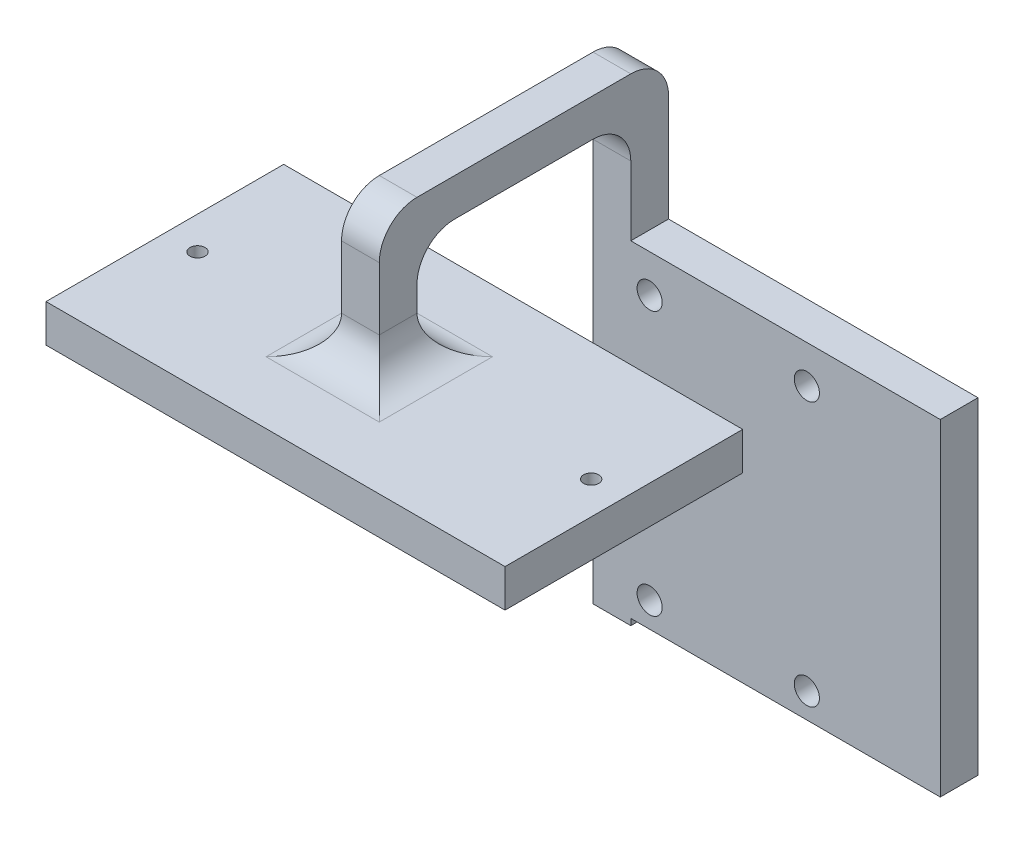
from build123d import *

# Parameters (mm, degrees)
IZIM1_W                                 = 40.658634346
IZIM1_H                                 = 22.072921898
Y_KSEKLIK_EKSTR_ZYON3_DEPTH             = 1.5
IZIM10_W                                = 40.658634346
IZIM10_H                                = 22.072921898
Y_KSEKLIK_EKSTR_ZYON5_DEPTH             = 1.5
Y_KSEKLIK_EKSTR_ZYON6_DEPTH             = 1.5
IZIM12_W                                = 40.658634346
IZIM12_H                                = 22.072921898
KES_EKSTR_ZYON1_DEPTH                   = 5
KES_EKSTR_ZYON1_DEPTH_BACK              = 3
RADYUS1_R                               = 3
Y_KSEKLIK_EKSTR_ZYON7_REACH             = 3.5
Y_KSEKLIK_EKSTR_ZYON7_DIRECTION_2_REACH = 31.45
IZIM18_R                                = 0.6
KES_EKSTR_ZYON3_DEPTH                   = 7
KES_EKSTR_ZYON3_DEPTH_BACK              = 3
SKETCH1_R                               = 1
CUT_EXTRUDE1_DEPTH                      = 3


with BuildPart() as part:
    # Çizim1 → Yükseklik-Ekstrüzyon3 (new body)
    with BuildSketch(Plane(origin=(0, 0, 0), x_dir=(1, 0, 0), z_dir=(0, 1, 0))):
        with Locations((1.2, 0)):
            Rectangle(IZIM1_W, IZIM1_H)
        with BuildLine():
            Line((1.9, -6.45), (1.9, -3.295349698))
            Line((1.9, -3.295349698), (16.626291793, -1.99221515))
            ThreePointArc((16.626291793, -1.99221515), (18.45, 0), (16.626291793, 1.99221515))
            Line((16.626291793, 1.99221515), (1.9, 3.295349698))
            Line((1.9, 3.295349698), (1.9, 6.45))
            ThreePointArc((1.9, 6.45), (0, 8.35), (-1.9, 6.45))
            Line((-1.9, 6.45), (-1.9, 2.87967012))
            ThreePointArc((-1.9, 2.87967012), (-2.057742862, 2.769150468), (-2.209072203, 2.65))
            Line((-2.209072203, 2.65), (-14.159121967, 1.99702088))
            ThreePointArc((-14.159121967, 1.99702088), (-16.05, 0), (-14.159121967, -1.99702088))
            Line((-14.159121967, -1.99702088), (-2.209072203, -2.65))
            ThreePointArc((-2.209072203, -2.65), (-2.057742862, -2.769150468), (-1.9, -2.87967012))
            Line((-1.9, -2.87967012), (-1.9, -6.45))
            ThreePointArc((-1.9, -6.45), (0, -8.35), (1.9, -6.45))
        make_face(mode=Mode.SUBTRACT)
    extrude(amount=Y_KSEKLIK_EKSTR_ZYON3_DEPTH)

    # Çizim10 → Yükseklik-Ekstrüzyon5 (add)
    with BuildSketch(Plane(origin=(0, 1.5, 0), x_dir=(1, 0, 0), z_dir=(0, 1, 0))):
        with Locations((1.2, 0)):
            Rectangle(IZIM10_W, IZIM10_H)
    extrude(amount=Y_KSEKLIK_EKSTR_ZYON5_DEPTH)

    # Çizim11 → Yükseklik-Ekstrüzyon6 (add, symmetric)
    with BuildSketch(Plane(origin=(0, 0, 0), x_dir=(0, 0, -1), z_dir=(1, 0, 0))):
        Polygon((18.5, 10.980931434), (1.5, 10.980931434), (1.5, 1.777726909), (-1.5, 1.777726909), (-1.5, 10.980931434), (-1.5, 13.980931434), (1.5, 13.980931434), (21.5, 13.980931434), (21.5, -24.019068566), (18.5, -24.019068566), align=None)
    extrude(amount=Y_KSEKLIK_EKSTR_ZYON6_DEPTH, both=True)

    # Çizim12 → Kes-Ekstrüzyon1 (cut, two sides)
    with BuildSketch(Plane(origin=(0, 0, 0), x_dir=(1, 0, 0), z_dir=(0, 1, 0))) as kes_ekstr_zyon1_sk:
        with Locations((1.2, 0)):
            Rectangle(IZIM12_W, IZIM12_H)
        Polygon((0, -9.45), (-17.05, -9.45), (-17.05, 9.45), (19.45, 9.45), (19.45, -9.45), align=None, mode=Mode.SUBTRACT)
    extrude(amount=KES_EKSTR_ZYON1_DEPTH, mode=Mode.SUBTRACT)
    extrude(kes_ekstr_zyon1_sk.sketch, amount=-KES_EKSTR_ZYON1_DEPTH_BACK, mode=Mode.SUBTRACT)

    # Radyus1
    radyus1_edges = [part.edges().sort_by_distance(p)[0] for p in [
        (-1.5, 3, 0),
        (0, 3, -1.5),
        (0, 3, 1.5),
        (1.5, 3, 0),
        (0, 13.980931434, -21.5),
        (0, 13.980931434, 1.5),
        (0, 10.980931434, -1.5),
        (0, 10.980931434, -18.5),
    ]]
    fillet(radyus1_edges, radius=RADYUS1_R)

    # Yükseklik-Ekstrüzyon7: up to this face of the body (flat: up to its plane)
    y_kseklik_ekstr_zyon7_end = Plane(part.part.faces().sort_by_distance((0, -6.519068566, -21.5))[0])
    # Çizim13 → Yükseklik-Ekstrüzyon7 (add, up to the picked face)
    with BuildSketch(Plane(origin=(0, 0, -20), x_dir=(-1, 0, 0), z_dir=(0, 0, -1)), mode=Mode.PRIVATE) as y_kseklik_ekstr_zyon7_sk1:
        Polygon((-26.108304445, 2.483027661), (-26.108304445, -23.516972339), (0.891695555, -23.516972339), (0.891695555, -2.497903773), (0.891695555, 2.483027661), align=None)
    y_kseklik_ekstr_zyon7_tool1 = split(extrude(y_kseklik_ekstr_zyon7_sk1.sketch, amount=Y_KSEKLIK_EKSTR_ZYON7_REACH, mode=Mode.PRIVATE), bisect_by=y_kseklik_ekstr_zyon7_end, keep=Keep.BOTH, mode=Mode.PRIVATE)
    add(y_kseklik_ekstr_zyon7_tool1.solids().sort_by_distance((12.608304, -10.516972, -20))[0])

    # Yükseklik-Ekstrüzyon7 direction 2: up to this face of the body (flat: up to its plane)
    y_kseklik_ekstr_zyon7_direction_2_end = Plane(part.part.faces().sort_by_distance((0, -8.019068566, -18.5))[0])
    # Çizim13 → Yükseklik-Ekstrüzyon7 direction 2 (add, up to the picked face)
    with BuildSketch(Plane(origin=(0, 0, -20), x_dir=(-1, 0, 0), z_dir=(0, 0, -1)), mode=Mode.PRIVATE) as y_kseklik_ekstr_zyon7_direction_2_sk1:
        Polygon((-26.108304445, 2.483027661), (-26.108304445, -23.516972339), (0.891695555, -23.516972339), (0.891695555, -2.497903773), (0.891695555, 2.483027661), align=None)
    y_kseklik_ekstr_zyon7_direction_2_tool1 = split(extrude(y_kseklik_ekstr_zyon7_direction_2_sk1.sketch, amount=-Y_KSEKLIK_EKSTR_ZYON7_DIRECTION_2_REACH, mode=Mode.PRIVATE), bisect_by=y_kseklik_ekstr_zyon7_direction_2_end, keep=Keep.BOTH, mode=Mode.PRIVATE)
    add(y_kseklik_ekstr_zyon7_direction_2_tool1.solids().sort_by_distance((12.608304, -10.516972, -20))[0])

    # Çizim18 → Kes-Ekstrüzyon3 (cut, two sides)
    with BuildSketch(Plane.XZ.offset(-1.5)) as kes_ekstr_zyon3_sk:
        with Locations((-14.45, 0)):
            Circle(IZIM18_R)
        with Locations((16.85, 0)):
            Circle(IZIM18_R)
    extrude(amount=KES_EKSTR_ZYON3_DEPTH, mode=Mode.SUBTRACT)
    extrude(kes_ekstr_zyon3_sk.sketch, amount=-KES_EKSTR_ZYON3_DEPTH_BACK, mode=Mode.SUBTRACT)

    # Sketch1 → Cut-Extrude1 (cut)
    with BuildSketch(Plane(origin=(0, 0, -21.5), x_dir=(-1, 0, 0), z_dir=(0, 0, -1))):
        with Locations((-2.999001891, -0.516972339)):
            Circle(SKETCH1_R)
        with Locations((-2.999001891, -21.516972339)):
            Circle(SKETCH1_R)
        with Locations((-15.499001891, -21.516972339)):
            Circle(SKETCH1_R)
        with Locations((-15.499001891, -0.516972339)):
            Circle(SKETCH1_R)
    extrude(amount=-CUT_EXTRUDE1_DEPTH, mode=Mode.SUBTRACT)


solid = part.part
